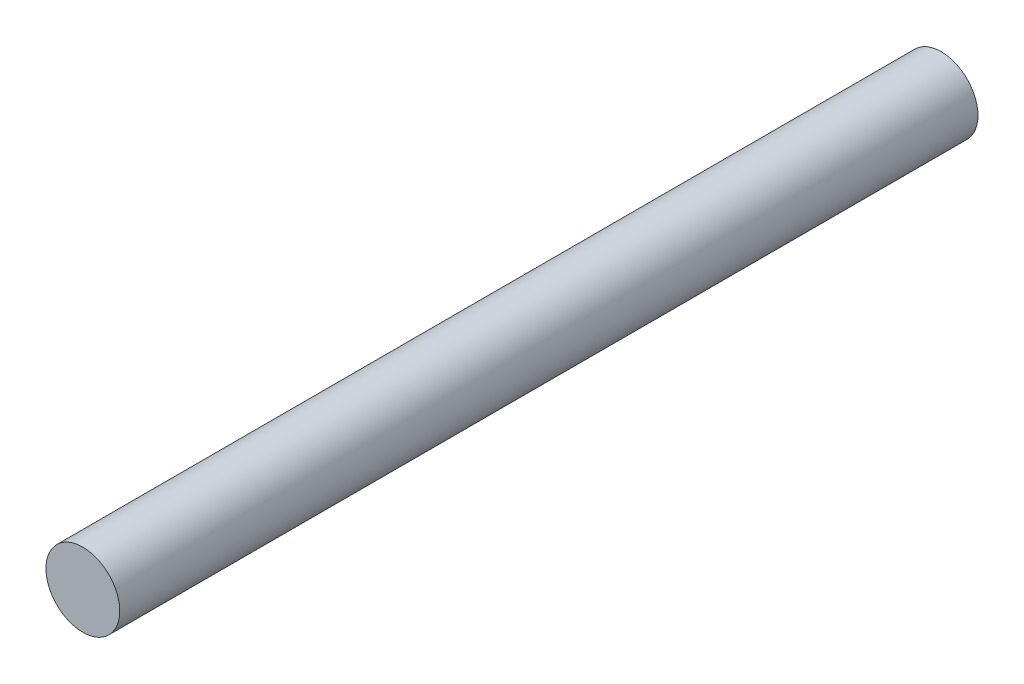
from build123d import *

# Parameters (mm, degrees)
SKETCH1_R           = 10.922
BOSS_EXTRUDE1_DEPTH = 254


with BuildPart() as part:
    # Sketch1 → Boss-Extrude1 (new body)
    with BuildSketch(Plane.XY):
        Circle(SKETCH1_R)
    extrude(amount=BOSS_EXTRUDE1_DEPTH)


solid = part.part
